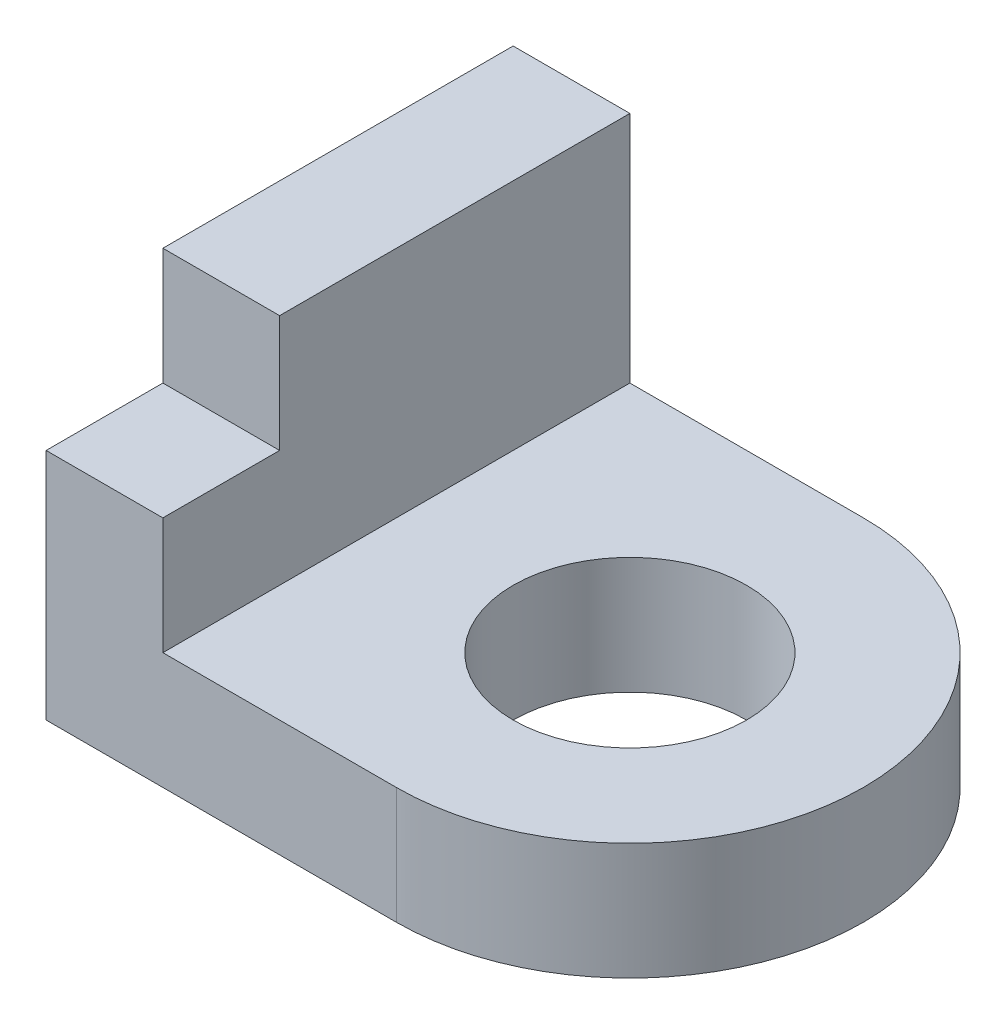
from build123d import *

# Parameters (mm, degrees)
SKETCH_1_R      = 5
EXTRUDE_1_DEPTH = 5
SKETCH_1_3_W    = 5
SKETCH_1_3_H    = 5
EXTRUDE_2_DEPTH = 10
SKETCH_1_4_W    = 5
SKETCH_1_4_H    = 15
EXTRUDE_3_DEPTH = 15
SCALE_1_SCALE   = 0.2


with BuildPart() as part:
    # 草圖1 → 填料-伸長1 (new body)
    with BuildSketch(Plane(origin=(0, 0, 0), x_dir=(1, 0, 0), z_dir=(0, 1, 0))):
        with BuildLine():
            ThreePointArc((0, -10), (10, 0), (0, 10))
            Line((0, 10), (-10, 10))
            Line((-10, 10), (-10, -5))
            Line((-10, -5), (-10, -10))
            Line((-10, -10), (0, -10))
        make_face()
        Circle(SKETCH_1_R, mode=Mode.SUBTRACT)
    extrude(amount=EXTRUDE_1_DEPTH)

    # 草圖1<3> → 填料-伸長2 (add)
    with BuildSketch(Plane(origin=(0, 0, 0), x_dir=(1, 0, 0), z_dir=(0, 1, 0))):
        with Locations((-12.5, -7.5)):
            Rectangle(SKETCH_1_3_W, SKETCH_1_3_H)
    extrude(amount=EXTRUDE_2_DEPTH)

    # 草圖1<4> → 填料-伸長3 (add)
    with BuildSketch(Plane(origin=(0, 0, 0), x_dir=(1, 0, 0), z_dir=(0, 1, 0))):
        with Locations((-12.5, 2.5)):
            Rectangle(SKETCH_1_4_W, SKETCH_1_4_H)
    extrude(amount=EXTRUDE_3_DEPTH)


with BuildPart() as part_1:
    # 縮放比例1: scaled about (-6.812216975, 4.758193472, -0.338729021)
    add(part.part.scale(SCALE_1_SCALE).moved(Location((-5.44977358, 3.806554778, -0.270983217))))


solid = part_1.part
